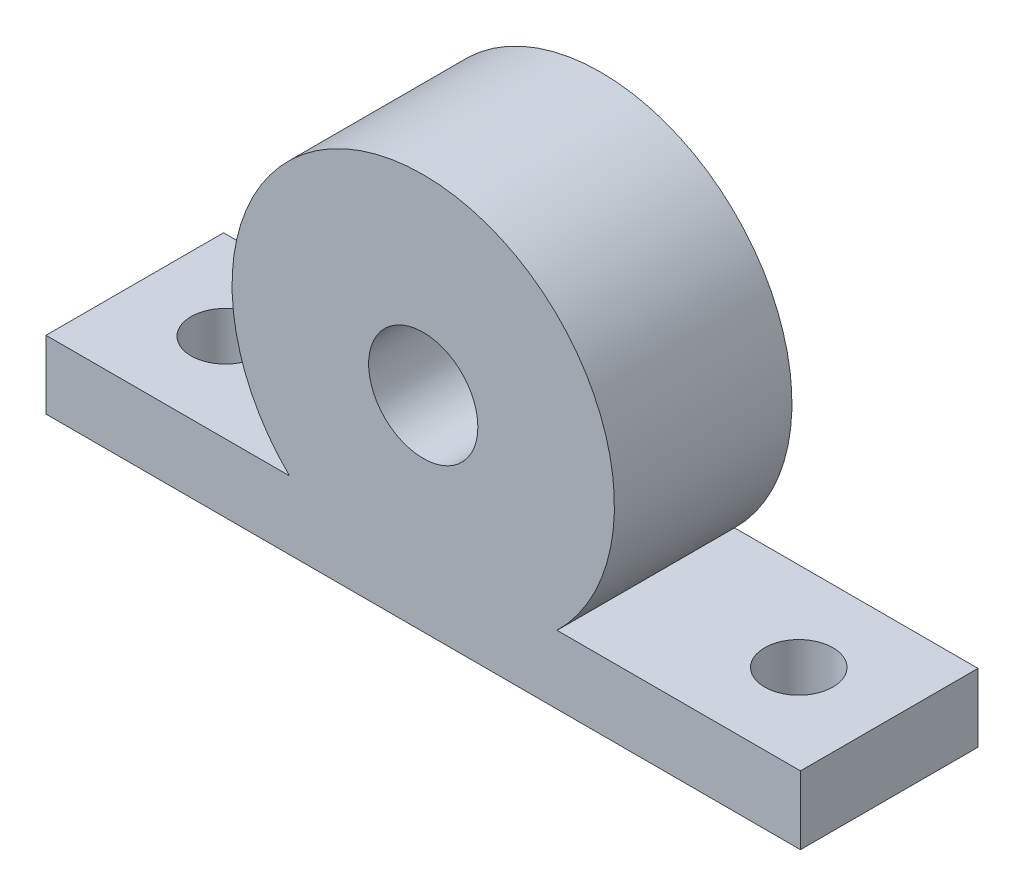
from build123d import *

# Parameters (mm, degrees)
SKETCH1_R           = 4
BOSS_EXTRUDE1_DEPTH = 13
SKETCH2_R           = 2.5
CUT_EXTRUDE1_DEPTH  = 30


with BuildPart() as part:
    # Sketch1 → Boss-Extrude1 (new body)
    with BuildSketch(Plane.XY):
        with BuildLine():
            Line((-27.625, -15), (27.625, -15))
            Line((27.625, -15), (27.625, -10))
            Line((27.625, -10), (9.797958971, -10))
            ThreePointArc((9.797958971, -10), (0, 14), (-9.797958971, -10))
            Line((-9.797958971, -10), (-27.625, -10))
            Line((-27.625, -10), (-27.625, -15))
        make_face()
        Circle(SKETCH1_R, mode=Mode.SUBTRACT)
    extrude(amount=BOSS_EXTRUDE1_DEPTH)

    # Sketch2 → Cut-Extrude1 (cut, through all)
    with BuildSketch(Plane.XZ.offset(15)):
        with Locations((-21, 6.5)):
            Circle(SKETCH2_R)
        with Locations((21, 6.5)):
            Circle(SKETCH2_R)
    extrude(amount=-CUT_EXTRUDE1_DEPTH, mode=Mode.SUBTRACT)


solid = part.part
